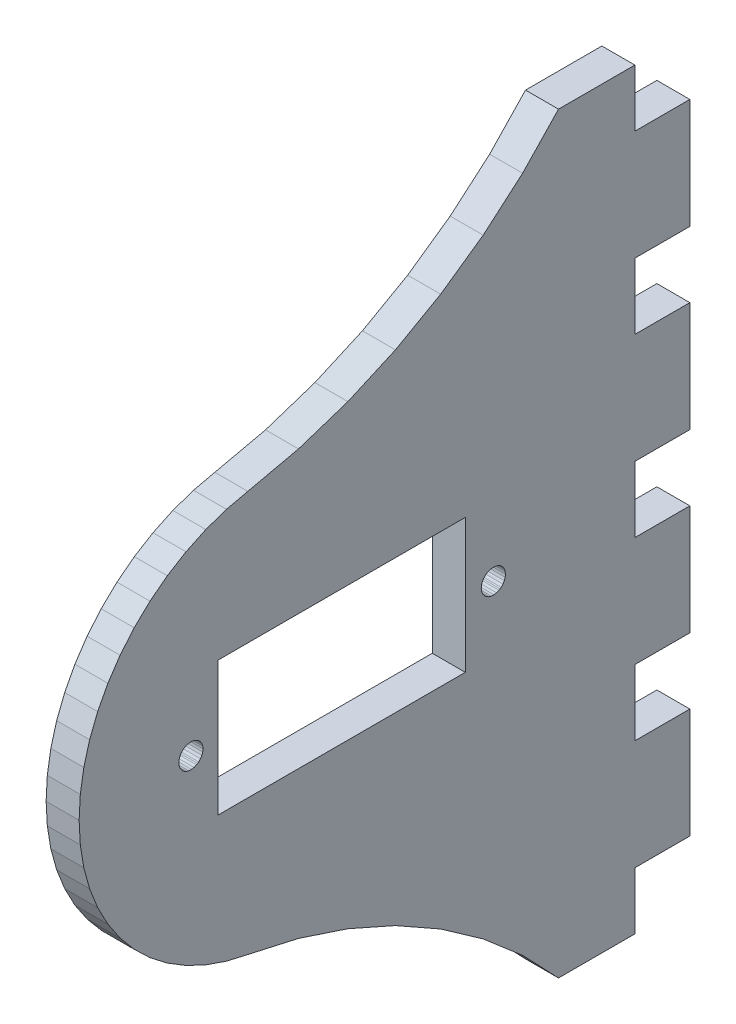
from build123d import *

# Parameters (mm, degrees)
SKETCH1_W           = 22.5
SKETCH1_H           = 12.2
BOSS_EXTRUDE1_DEPTH = 3.000000026


with BuildPart() as part:
    # Sketch1 → Boss-Extrude1 (new body)
    with BuildSketch(Plane(origin=(3.000000026, 0, 0), x_dir=(0, 0, -1), z_dir=(1, 0, 0))):
        Polygon((-21.320657805, 14.036174864), (-22.758102044, 12.659284286), (-24.039382115, 11.136000976), (-25.149684399, 9.483940899), (-26.076165959, 7.722207811), (-26.808116585, 5.871174857), (-27.337068692, 3.952247556), (-27.656905353, 1.987616299), (-27.763931081, 0), (-27.656905353, -1.987616299), (-27.337068692, -3.952247556), (-26.808116585, -5.871174857), (-26.076165959, -7.722207811), (-25.149684399, -9.483940899), (-24.039382115, -11.136000976), (-22.758102044, -12.659284286), (-21.320657805, -14.036174864), (-19.743673503, -15.250750817), (-18.045384437, -16.28896594), (-16.245434061, -17.138814554), (-14.364630915, -17.790470272), (-12.424727902, -18.236396834), (-7.814312354, -19.272558391), (-3.327161307, -20.754124969), (0.993806054, -22.666925564), (5.107260309, -24.992663413), (8.973857388, -27.709092945), (12.55661156, -30.790233985), (15.821257606, -34.206613898), (22.763932127, -34.206613898), (22.763932127, -28.999887407), (27.763931084, -28.999887407), (27.763931084, -18.99988763), (22.763932127, -18.99988763), (22.763932127, -12.999887578), (27.763931084, -12.999887578), (27.763931084, -2.999887569), (22.763932127, -2.999887569), (22.763932127, 3.000112483), (27.763931084, 3.000112483), (27.763931084, 13.000112027), (22.763932127, 13.000112027), (22.763932127, 19.00011301), (27.763931084, 19.00011301), (27.763931084, 29.000112787), (22.763932127, 29.000112787), (22.763932127, 34.206613898), (15.821257606, 34.206613898), (12.55661156, 30.790233985), (8.973857388, 27.709092945), (5.107260309, 24.992661551), (0.993806054, 22.666923702), (-3.327161307, 20.754123107), (-7.814312354, 19.272556528), (-12.424727902, 18.236394972), (-14.364630915, 17.790470272), (-16.245434061, 17.138814554), (-18.045384437, 16.28896594), (-19.743673503, 15.250750817), align=None)
        with Locations((-3.903931454, 0.199999778)):
            Rectangle(SKETCH1_W, SKETCH1_H, mode=Mode.SUBTRACT)
        Polygon((-18.119180575, 0.971863221), (-17.898211256, 1.059905044), (-17.663484439, 1.098386711), (-17.425971106, 1.085509197), (-17.196778208, 1.02187437), (-16.986625269, 0.910457922), (-16.891805455, 0.83837827), (-16.728227958, 0.665691623), (-16.605598852, 0.461878022), (-16.529647633, 0.236467487), (-16.503928229, 0), (-16.529647633, -0.236467487), (-16.605598852, -0.461878022), (-16.728227958, -0.665691623), (-16.891805455, -0.83837827), (-16.986625269, -0.910457922), (-17.088681459, -0.971863221), (-17.309648916, -1.059905044), (-17.544377595, -1.098386711), (-17.781890929, -1.085509197), (-18.011083826, -1.02187437), (-18.221236765, -0.910457922), (-18.402526155, -0.756469381), (-18.546473235, -0.567109266), (-18.64635013, -0.351231691), (-18.697483465, -0.118930919), (-18.70393008, 0), (-18.678214401, 0.236467487), (-18.602263182, 0.461878022), (-18.479634076, 0.665691623), (-18.316056579, 0.83837827), align=None, mode=Mode.SUBTRACT)
        Polygon((9.380819276, 0.971863221), (9.601787664, 1.059905044), (9.836516343, 1.098386711), (10.074028745, 1.085509197), (10.303220712, 1.02187437), (10.513374582, 0.910457922), (10.608193465, 0.83837827), (10.771771893, 0.665691623), (10.89440193, 0.461878022), (10.970351286, 0.236467487), (10.996068828, 0), (10.970351286, -0.236467487), (10.89440193, -0.461878022), (10.771771893, -0.665691623), (10.608193465, -0.83837827), (10.513374582, -0.910457922), (10.411318392, -0.971863221), (10.190350004, -1.059905044), (9.955622256, -1.098386711), (9.718108922, -1.085509197), (9.488916956, -1.02187437), (9.278763086, -0.910457922), (9.097473696, -0.756469381), (8.953525685, -0.567109266), (8.853650652, -0.351231691), (8.802517317, -0.118930919), (8.79606884, 0), (8.821786381, 0.236467487), (8.897735737, 0.461878022), (9.020366706, 0.665691623), (9.183944203, 0.83837827), align=None, mode=Mode.SUBTRACT)
    extrude(amount=-BOSS_EXTRUDE1_DEPTH)


solid = part.part
